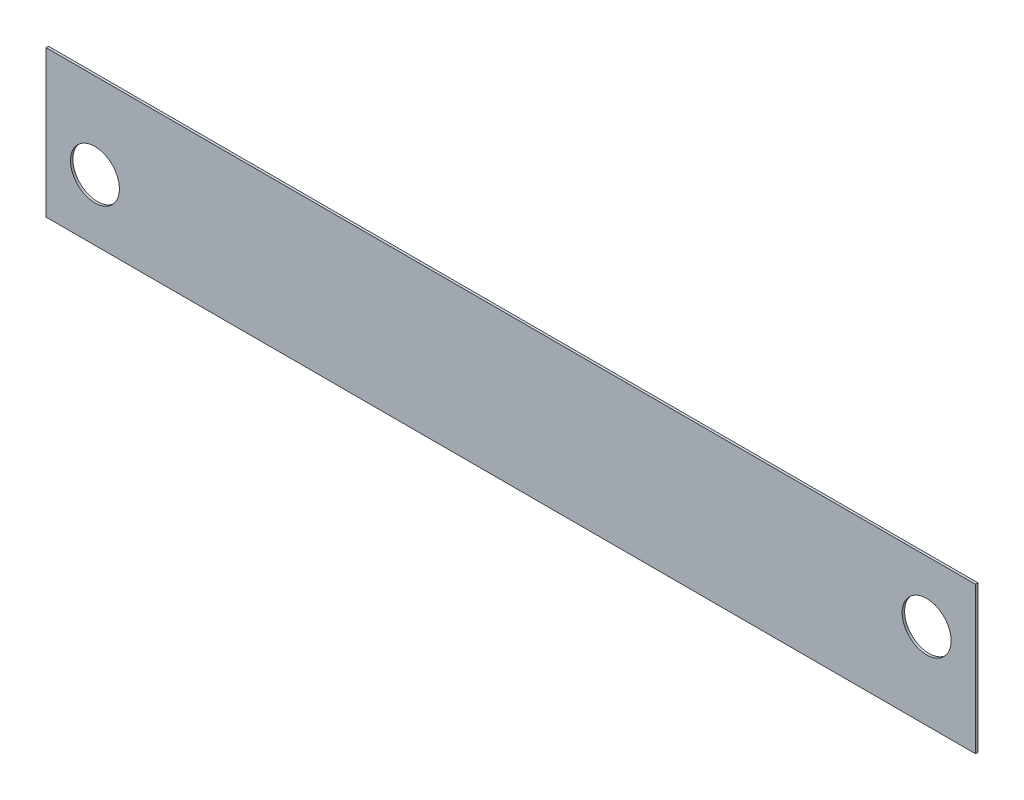
from build123d import *

# Parameters (mm, degrees)
SKETCH1_W      = 380
SKETCH1_H      = 60
SKETCH1_R      = 10
EXTRUDE1_DEPTH = 1


with BuildPart() as part:
    # Sketch1 → Extrude1 (new body)
    with BuildSketch(Plane.XY):
        with Locations((170, 5)):
            Rectangle(SKETCH1_W, SKETCH1_H)
        Circle(SKETCH1_R, mode=Mode.SUBTRACT)
        with Locations((340, 10)):
            Circle(SKETCH1_R, mode=Mode.SUBTRACT)
    extrude(amount=EXTRUDE1_DEPTH)


solid = part.part
